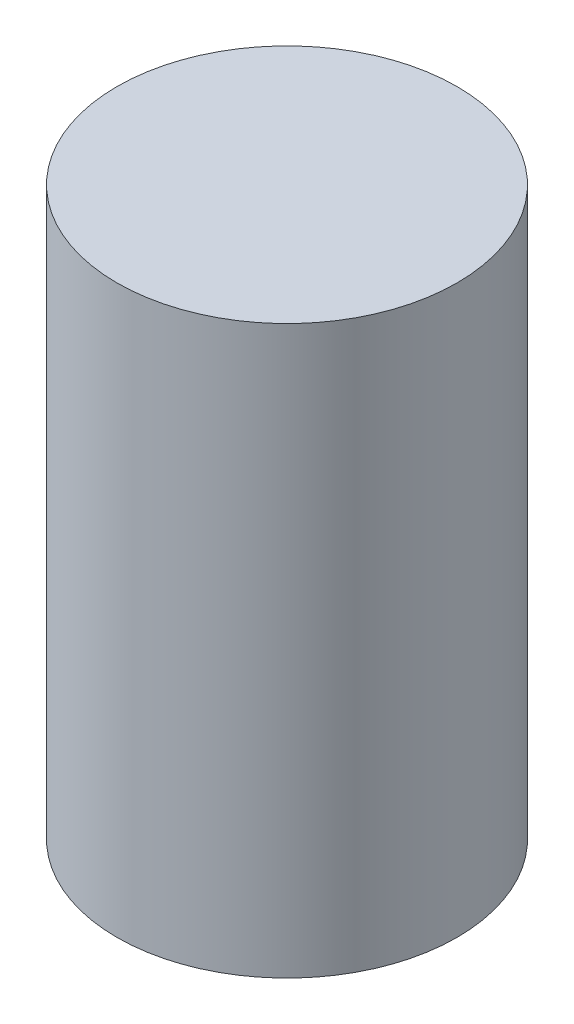
from build123d import *

# Parameters (mm, degrees)
SKETCH2_R           = 22.5
BOSS_EXTRUDE1_DEPTH = 75


with BuildPart() as part:
    # Sketch2 → Boss-Extrude1 (new body)
    with BuildSketch(Plane(origin=(0, 0, 0), x_dir=(1, 0, 0), z_dir=(0, 1, 0))):
        Circle(SKETCH2_R)
    extrude(amount=BOSS_EXTRUDE1_DEPTH)


solid = part.part
